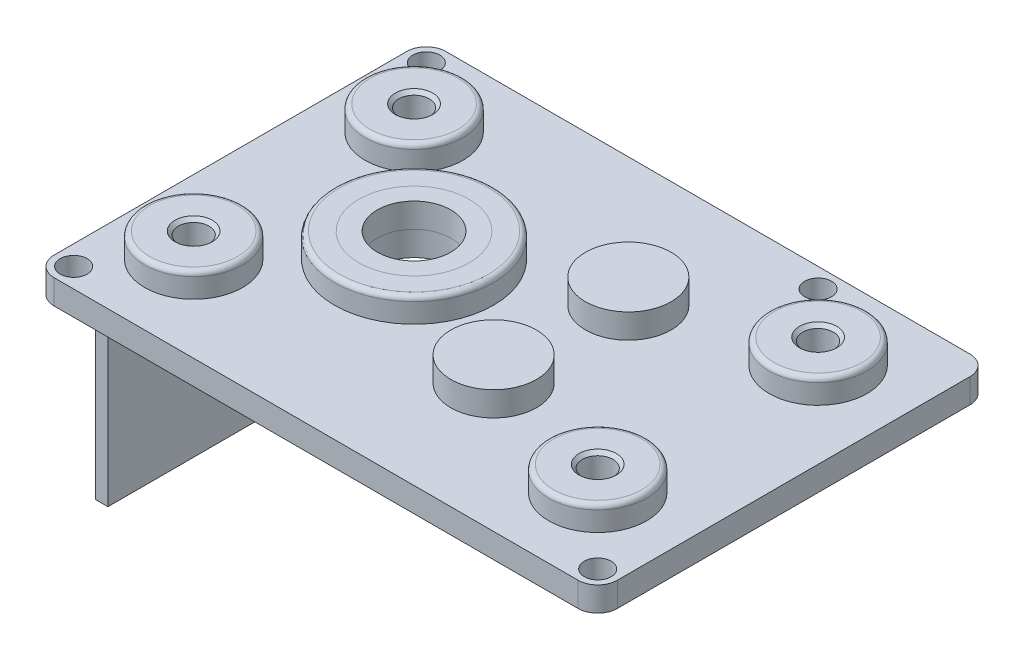
from build123d import *

# Parameters (mm, degrees)
SKETCH2_W                     = 46
SKETCH2_H                     = 32
BOSS_EXTRUDE2_DEPTH           = 2
SKETCH6_R                     = 3
CUT_EXTRUDE1_DEPTH            = 3
SKETCH7_R                     = 4.5
SKETCH7_R_2                   = 3
BOSS_EXTRUDE4_DEPTH           = 2
SKETCH8_R                     = 6.5
SKETCH8_R_2                   = 4.5
BOSS_EXTRUDE5_DEPTH           = 2
SKETCH3_R                     = 4
BOSS_EXTRUDE3_DEPTH           = 2
FILLET3_R                     = 0.4
LPATTERN1_COUNT               = 2
LPATTERN1_PITCH               = 33
SKETCH9_R                     = 3.5
BOSS_EXTRUDE6_DEPTH           = 2
MIRROR2_COPY_1_SKETCH_R       = 4
MIRROR2_COPY_1_DEPTH          = 2
SKETCH10_W                    = 1.1
SKETCH10_H                    = 2
M2_CLEARANCE_HOLE1_AT_2_COUNT = 2
M2_CLEARANCE_HOLE1_AT_2_PITCH = 32
M2_CLEARANCE_HOLE1_AT_3_COUNT = 2
M2_CLEARANCE_HOLE1_AT_3_PITCH = 51.587595408
M2_CLEARANCE_HOLE1_AT_4_COUNT = 2
M2_CLEARANCE_HOLE1_AT_4_PITCH = 28.8
FILLET1_R                     = 1.6
SKETCH12_W                    = 1
SKETCH12_H                    = 22
BOSS_EXTRUDE7_DEPTH           = 17
FILLET5_R                     = 0.4


with BuildPart() as part:
    # Sketch2 → Boss-Extrude2 (new body)
    with BuildSketch(Plane(origin=(0, 0, 0), x_dir=(1, 0, 0), z_dir=(0, 1, 0))):
        with Locations((8, 0)):
            Rectangle(SKETCH2_W, SKETCH2_H)
    extrude(amount=BOSS_EXTRUDE2_DEPTH)

    # Sketch6 → Cut-Extrude1 (cut, through all)
    with BuildSketch(Plane(origin=(0, 2, 0), x_dir=(1, 0, 0), z_dir=(0, 1, 0))):
        Circle(SKETCH6_R)
    extrude(amount=-CUT_EXTRUDE1_DEPTH, mode=Mode.SUBTRACT)

    # Sketch3 → Boss-Extrude3 (add)
    with BuildSketch(Plane(origin=(0, 2, 0), x_dir=(1, 0, 0), z_dir=(0, 1, 0))):
        with Locations((-9, 9)):
            Circle(SKETCH3_R)
    boss_extrude3 = extrude(amount=BOSS_EXTRUDE3_DEPTH)

    # Sketch4 → M3x0.5 Tapped Hole1 (revolve, cut)
    with BuildSketch(Plane(origin=(-9, 4, -9), x_dir=(0, 0, 1), z_dir=(1, 0, 0))):
        Polygon((0, 0), (0, 4), (1.25, 4), (1.25, 0.275), (1.525, 0), align=None)
    m3x0_5_tapped_hole1 = revolve(axis=Axis((-9, 10.35, -9), (0, -1, 0)), mode=Mode.SUBTRACT)

    # LPattern1: Boss-Extrude3, M3x0.5 Tapped Hole1 ×2
    with Locations(*[(i * LPATTERN1_PITCH, 0, 0) for i in range(1, LPATTERN1_COUNT)]):
        add(boss_extrude3)
        add(m3x0_5_tapped_hole1, mode=Mode.SUBTRACT)

    # Sketch9 → Boss-Extrude6 (add)
    with BuildSketch(Plane(origin=(0, 2, 0), x_dir=(1, 0, 0), z_dir=(0, 1, 0))):
        with Locations((12, 5.5)):
            Circle(SKETCH9_R)
    boss_extrude6 = extrude(amount=BOSS_EXTRUDE6_DEPTH)

    # Mirror2: Boss-Extrude3, M3x0.5 Tapped Hole1 across plane
    add(boss_extrude3.mirror(Plane.XY))
    add(m3x0_5_tapped_hole1.mirror(Plane.XY), mode=Mode.SUBTRACT)

    # Mirror2 copy 1 sketch → Mirror2 copy 1 (add)
    with BuildSketch(Plane(origin=(33, 2, 0), x_dir=(1, 0, 0), z_dir=(0, 1, 0))):
        with Locations((-9, -9)):
            Circle(MIRROR2_COPY_1_SKETCH_R)
    extrude(amount=MIRROR2_COPY_1_DEPTH)

    # Mirror2 copy 2 sketch → Mirror2 copy 2 (revolve, cut)
    with BuildSketch(Plane(origin=(24, 4, 9), x_dir=(0, 0, -1), z_dir=(1, 0, 0))):
        Polygon((0, 0), (0, -4), (1.25, -4), (1.25, -0.275), (1.525, 0), align=None)
    revolve(axis=Axis((24, 10.35, 9), (0, 1, 0)), mode=Mode.SUBTRACT)

    # Mirror3: Boss-Extrude6 across plane
    add(boss_extrude6.mirror(Plane.XY))

    # Sketch10 → M2 Clearance Hole1 (revolve, cut)
    with BuildSketch(Plane(origin=(-13.4, 2, -14.4), x_dir=(0, 0, 1), z_dir=(1, 0, 0))):
        with Locations((0.55, 1)):
            Rectangle(SKETCH10_W, SKETCH10_H)
    m2_clearance_hole1 = revolve(axis=Axis((-13.4, 8.35, -14.4), (0, -1, 0)), mode=Mode.SUBTRACT)

    # M2 Clearance Hole1 at 2: M2 Clearance Hole1 ×2
    with Locations(*[(i * M2_CLEARANCE_HOLE1_AT_2_PITCH, 0, 0) for i in range(1, M2_CLEARANCE_HOLE1_AT_2_COUNT)]):
        add(m2_clearance_hole1, mode=Mode.SUBTRACT)

    # M2 Clearance Hole1 at 3: M2 Clearance Hole1 ×2
    with Locations(*[Vector(0.829656813, 0, 0.558273743) * (i * M2_CLEARANCE_HOLE1_AT_3_PITCH) for i in range(1, M2_CLEARANCE_HOLE1_AT_3_COUNT)]):
        add(m2_clearance_hole1, mode=Mode.SUBTRACT)

    # M2 Clearance Hole1 at 4: M2 Clearance Hole1 ×2
    with Locations(*[(0, 0, i * M2_CLEARANCE_HOLE1_AT_4_PITCH) for i in range(1, M2_CLEARANCE_HOLE1_AT_4_COUNT)]):
        add(m2_clearance_hole1, mode=Mode.SUBTRACT)

    # Fillet1
    fillet1_edges = [part.edges().sort_by_distance(p)[0] for p in [
        (-15, 1, -16),
        (31, 1, -16),
        (31, 1, 16),
        (-15, 1, 16),
    ]]
    fillet(fillet1_edges, radius=FILLET1_R)

    # Sketch12 → Boss-Extrude7 (add)
    with BuildSketch(Plane.XZ):
        with Locations((-14.5, 0)):
            Rectangle(SKETCH12_W, SKETCH12_H)
    extrude(amount=BOSS_EXTRUDE7_DEPTH)

    # Fillet5
    fillet5_edges = [part.edges().sort_by_distance(p)[0] for p in [
        (-13, 4, -9),
        (20, 4, -9),
        (-13, 4, 9),
        (20, 4, 9),
    ]]
    fillet(fillet5_edges, radius=FILLET5_R)


with BuildPart() as body_2:
    # Sketch7 → Boss-Extrude4 (new body)
    with BuildSketch(Plane(origin=(0, 2, 0), x_dir=(1, 0, 0), z_dir=(0, 1, 0))):
        Circle(SKETCH7_R)
        Circle(SKETCH7_R_2, mode=Mode.SUBTRACT)
    extrude(amount=BOSS_EXTRUDE4_DEPTH)


with BuildPart() as body_3:
    # Sketch8 → Boss-Extrude5 (new body)
    with BuildSketch(Plane(origin=(0, 2, 0), x_dir=(1, 0, 0), z_dir=(0, 1, 0))):
        Circle(SKETCH8_R)
        Circle(SKETCH8_R_2, mode=Mode.SUBTRACT)
    extrude(amount=BOSS_EXTRUDE5_DEPTH)

    # Fillet3
    fillet3_edges = [body_3.edges().sort_by_distance(p)[0] for p in [
        (-6.5, 4, 0),
    ]]
    fillet(fillet3_edges, radius=FILLET3_R)


solid = Compound([part.part, body_2.part, body_3.part])
